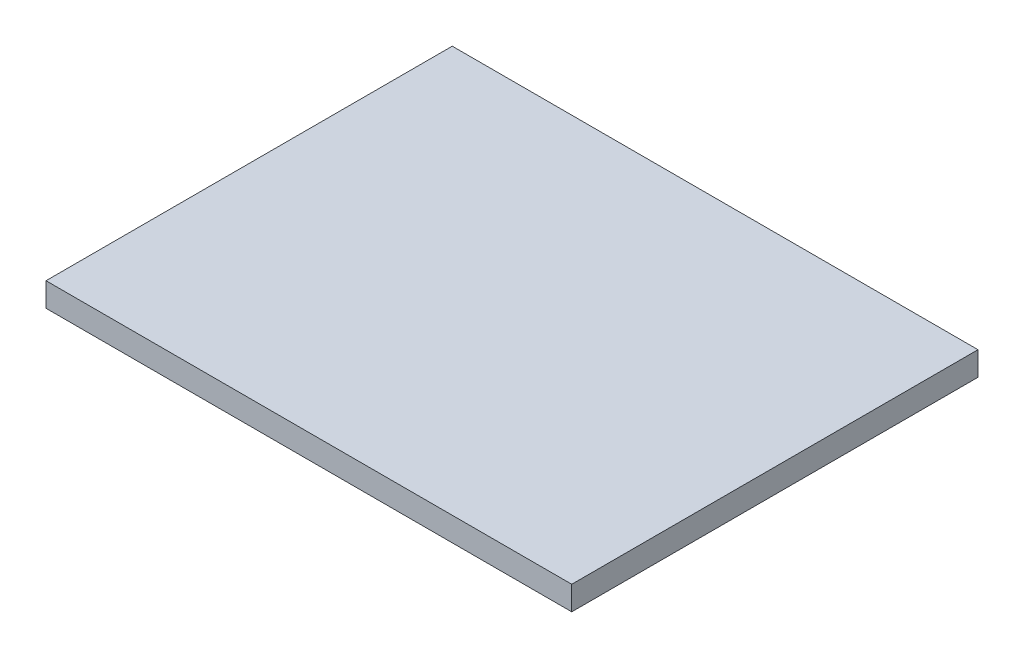
from build123d import *

# Parameters (mm, degrees)
SKETCH_1_W      = 44
SKETCH_1_H      = 34
EXTRUDE_1_DEPTH = 2


with BuildPart() as part:
    # 草图1 → 凸台-拉伸1 (new body)
    with BuildSketch(Plane(origin=(0, 0, 0), x_dir=(1, 0, 0), z_dir=(0, 1, 0))):
        Rectangle(SKETCH_1_W, SKETCH_1_H)
    extrude(amount=EXTRUDE_1_DEPTH)


solid = part.part
